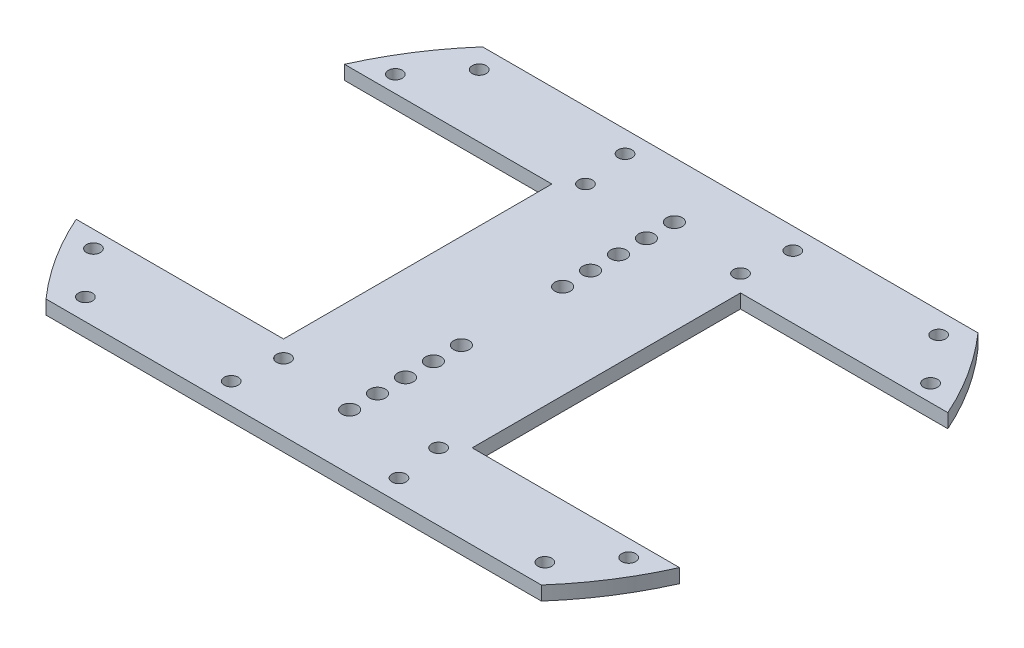
from build123d import *

# Parameters (mm, degrees)
SKETCH1_R           = 75
BOSS_EXTRUDE1_DEPTH = 3.175
CUT_EXTRUDE1_DEPTH  = 3.175
SKETCH3_R           = 1.778
SKETCH3_R_2         = 1.5875
CUT_EXTRUDE2_DEPTH  = 3.175
SKETCH4_R           = 1.5875
CUT_EXTRUDE3_DEPTH  = 3.175
CUT_EXTRUDE4_DEPTH  = 3.175


with BuildPart() as part:
    # Sketch1 → Boss-Extrude1 (new body)
    with BuildSketch(Plane(origin=(0, 0, 0), x_dir=(1, 0, 0), z_dir=(0, 1, 0))):
        Circle(SKETCH1_R)
    extrude(amount=BOSS_EXTRUDE1_DEPTH)

    # Sketch2 → Cut-Extrude1 (cut)
    with BuildSketch(Plane(origin=(0, 3.175, 0), x_dir=(1, 0, 0), z_dir=(0, 1, 0))):
        with BuildLine():
            Line((-56.262005909, -49.594220339), (56.262005909, -49.594220339))
            ThreePointArc((56.262005909, -49.594220339), (0, -75), (-56.262005909, -49.594220339))
        make_face()
        with BuildLine():
            Line((-56.262005909, 49.594220339), (56.262005909, 49.594220339))
            ThreePointArc((56.262005909, 49.594220339), (0, 75), (-56.262005909, 49.594220339))
        make_face()
    extrude(amount=-CUT_EXTRUDE1_DEPTH, mode=Mode.SUBTRACT)

    # Sketch3 → Cut-Extrude2 (cut)
    with BuildSketch(Plane(origin=(0, 3.175, 0), x_dir=(1, 0, 0), z_dir=(0, 1, 0))):
        with Locations((0, 36.894220339)):
            Circle(SKETCH3_R)
        with Locations((0, 11.494220339)):
            Circle(SKETCH3_R)
        with Locations((0, 17.844220339)):
            Circle(SKETCH3_R)
        with Locations((0, 24.194220339)):
            Circle(SKETCH3_R)
        with Locations((0, 30.544220339)):
            Circle(SKETCH3_R)
        with Locations((0, -11.494220339)):
            Circle(SKETCH3_R)
        with Locations((0, -17.844220339)):
            Circle(SKETCH3_R)
        with Locations((0, -24.194220339)):
            Circle(SKETCH3_R)
        with Locations((0, -30.544220339)):
            Circle(SKETCH3_R)
        with Locations((0, -36.894220339)):
            Circle(SKETCH3_R)
        with Locations((-52.180304588, -44.729838125)):
            Circle(SKETCH3_R_2)
        with Locations((52.180304588, -44.729838125)):
            Circle(SKETCH3_R_2)
        with Locations((52.180304588, 44.729838125)):
            Circle(SKETCH3_R_2)
        with Locations((-52.180304588, 44.729838125)):
            Circle(SKETCH3_R_2)
        with Locations((-19.05, 44.729838125)):
            Circle(SKETCH3_R_2)
        with Locations((-19.05, -44.729838125)):
            Circle(SKETCH3_R_2)
        with Locations((19.05, -44.729838125)):
            Circle(SKETCH3_R_2)
        with Locations((19.05, 44.729838125)):
            Circle(SKETCH3_R_2)
    extrude(amount=-CUT_EXTRUDE2_DEPTH, mode=Mode.SUBTRACT)

    # Sketch4 → Cut-Extrude3 (cut)
    with BuildSketch(Plane(origin=(0, 3.175, 0), x_dir=(1, 0, 0), z_dir=(0, 1, 0))):
        with Locations((-60.791780161, 34.29)):
            Circle(SKETCH4_R)
        with Locations((-17.611780161, 34.29)):
            Circle(SKETCH4_R)
        with Locations((-17.611780161, -34.29)):
            Circle(SKETCH4_R)
        with Locations((-60.791780161, -34.29)):
            Circle(SKETCH4_R)
    cut_extrude3 = extrude(amount=-CUT_EXTRUDE3_DEPTH, mode=Mode.SUBTRACT)

    # Sketch5 → Cut-Extrude4 (cut)
    with BuildSketch(Plane(origin=(0, 3.175, 0), x_dir=(1, 0, 0), z_dir=(0, 1, 0))):
        with BuildLine():
            Line((-68.527144986, 30.48), (-21.421780161, 30.48))
            Line((-21.421780161, 30.48), (-21.421780161, -30.48))
            Line((-21.421780161, -30.48), (-68.527144986, -30.48))
            ThreePointArc((-68.527144986, -30.48), (-75, 0), (-68.527144986, 30.48))
        make_face()
    cut_extrude4 = extrude(amount=-CUT_EXTRUDE4_DEPTH, mode=Mode.SUBTRACT)

    # Mirror1: Cut-Extrude3, Cut-Extrude4 across plane
    add(cut_extrude3.mirror(Plane(origin=(0, 0, 0), x_dir=(0, 0, 1), z_dir=(1, 0, 0))), mode=Mode.SUBTRACT)
    add(cut_extrude4.mirror(Plane(origin=(0, 0, 0), x_dir=(0, 0, 1), z_dir=(1, 0, 0))), mode=Mode.SUBTRACT)


solid = part.part
